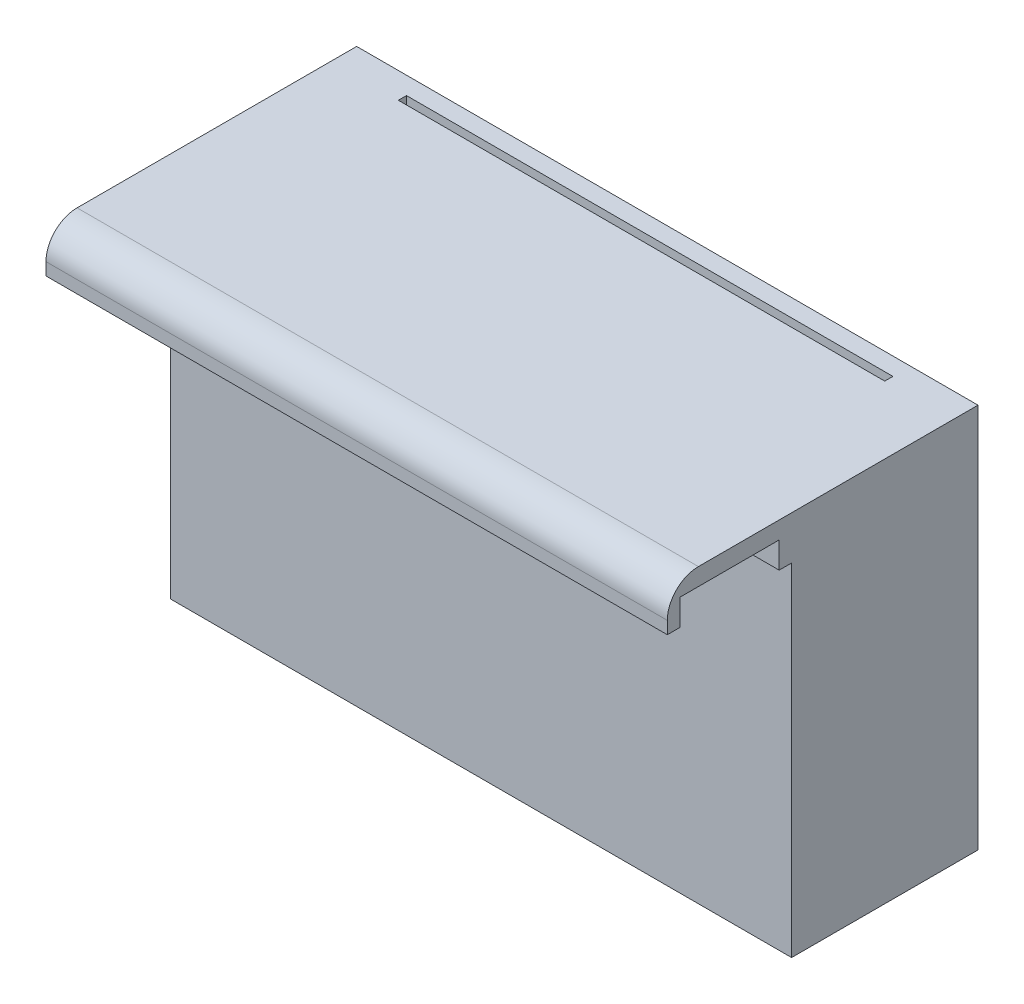
from build123d import *

# Parameters (mm, degrees)
SKETCH1_W           = 100
SKETCH1_H           = 20
BOSS_EXTRUDE1_DEPTH = 7
SKETCH2_W           = 16
SKETCH2_H           = 8.428142516
CUT_EXTRUDE1_DEPTH  = 101
SKETCH3_W           = 100
SKETCH3_H           = 62
BOSS_EXTRUDE2_DEPTH = 30
SKETCH4_W           = 88
SKETCH4_H           = 56.5
CUT_EXTRUDE2_DEPTH  = 27.5
SKETCH5_W           = 7.686328358
SKETCH5_H           = 52.5
CUT_EXTRUDE3_DEPTH  = 7
SKETCH6_W           = 27.5
SKETCH6_H           = 13
CUT_EXTRUDE4_DEPTH  = 3
SKETCH7_W           = 58
SKETCH7_H           = 2.3
CUT_EXTRUDE5_DEPTH  = 23
CUT_EXTRUDE6_DEPTH  = 23
SKETCH10_W          = 78.288889142
SKETCH10_H          = 1.311621563
CUT_EXTRUDE7_DEPTH  = 2
FILLET2_R           = 5


with BuildPart() as part:
    # Sketch1 → Boss-Extrude1 (new body)
    with BuildSketch(Plane(origin=(0, 0, 0), x_dir=(1, 0, 0), z_dir=(0, 1, 0))):
        with Locations((-50, 10)):
            Rectangle(SKETCH1_W, SKETCH1_H)
    extrude(amount=BOSS_EXTRUDE1_DEPTH)

    # Sketch2 → Cut-Extrude1 (cut, through all)
    with BuildSketch(Plane.ZY.offset(100)):
        with Locations((-10, 0)):
            Rectangle(SKETCH2_W, SKETCH2_H)
    extrude(amount=-CUT_EXTRUDE1_DEPTH, mode=Mode.SUBTRACT)

    # Sketch3 → Boss-Extrude2 (add)
    with BuildSketch(Plane(origin=(0, 0, -20), x_dir=(-1, 0, 0), z_dir=(0, 0, -1))):
        with Locations((50, -24)):
            Rectangle(SKETCH3_W, SKETCH3_H)
    extrude(amount=BOSS_EXTRUDE2_DEPTH)

    # Sketch4 → Cut-Extrude2 (cut)
    with BuildSketch(Plane(origin=(0, 0, -50), x_dir=(-1, 0, 0), z_dir=(0, 0, -1))):
        with Locations((50, -24)):
            Rectangle(SKETCH4_W, SKETCH4_H)
    extrude(amount=-CUT_EXTRUDE2_DEPTH, mode=Mode.SUBTRACT)

    # Sketch5 → Cut-Extrude3 (cut, through all)
    with BuildSketch(Plane(origin=(-94, 0, 0), x_dir=(0, 0, -1), z_dir=(1, 0, 0))):
        with Locations((35.043164179, -24)):
            Rectangle(SKETCH5_W, SKETCH5_H)
    extrude(amount=-CUT_EXTRUDE3_DEPTH, mode=Mode.SUBTRACT)

    # Sketch6 → Cut-Extrude4 (cut)
    with BuildSketch(Plane.ZY.offset(6)):
        with Locations((-36.25, -24)):
            Rectangle(SKETCH6_W, SKETCH6_H)
    extrude(amount=-CUT_EXTRUDE4_DEPTH, mode=Mode.SUBTRACT)

    # Sketch7 → Cut-Extrude5 (cut)
    with BuildSketch(Plane(origin=(0, 0, -50), x_dir=(-1, 0, 0), z_dir=(0, 0, -1))):
        with Locations((35, -53.4)):
            Rectangle(SKETCH7_W, SKETCH7_H)
    extrude(amount=-CUT_EXTRUDE5_DEPTH, mode=Mode.SUBTRACT)

    # Sketch9 → Cut-Extrude6 (cut)
    with BuildSketch(Plane(origin=(0, -52.25, 0), x_dir=(1, 0, 0), z_dir=(0, 1, 0))):
        Polygon((-37.960647242, 38.5), (-64, 38.5), (-64, 33.5), (-37.960647242, 33.5), (-6.413001969, 33.5), (-6.413001969, 38.5), align=None)
    extrude(amount=-CUT_EXTRUDE6_DEPTH, mode=Mode.SUBTRACT)

    # Sketch10 → Cut-Extrude7 (cut)
    with BuildSketch(Plane(origin=(0, 7, 0), x_dir=(1, 0, 0), z_dir=(0, 1, 0))):
        with Locations((-50, 46.502804438)):
            Rectangle(SKETCH10_W, SKETCH10_H)
    cut_extrude7 = extrude(amount=-CUT_EXTRUDE7_DEPTH, mode=Mode.SUBTRACT)

    # Mirror1: Cut-Extrude7 across plane
    add(cut_extrude7.mirror(Plane.ZX.offset(-24)), mode=Mode.SUBTRACT)

    # Fillet2
    fillet2_edges = [part.edges().sort_by_distance(p)[0] for p in [
        (-50, 7, 0),
    ]]
    fillet(fillet2_edges, radius=FILLET2_R)


solid = part.part
